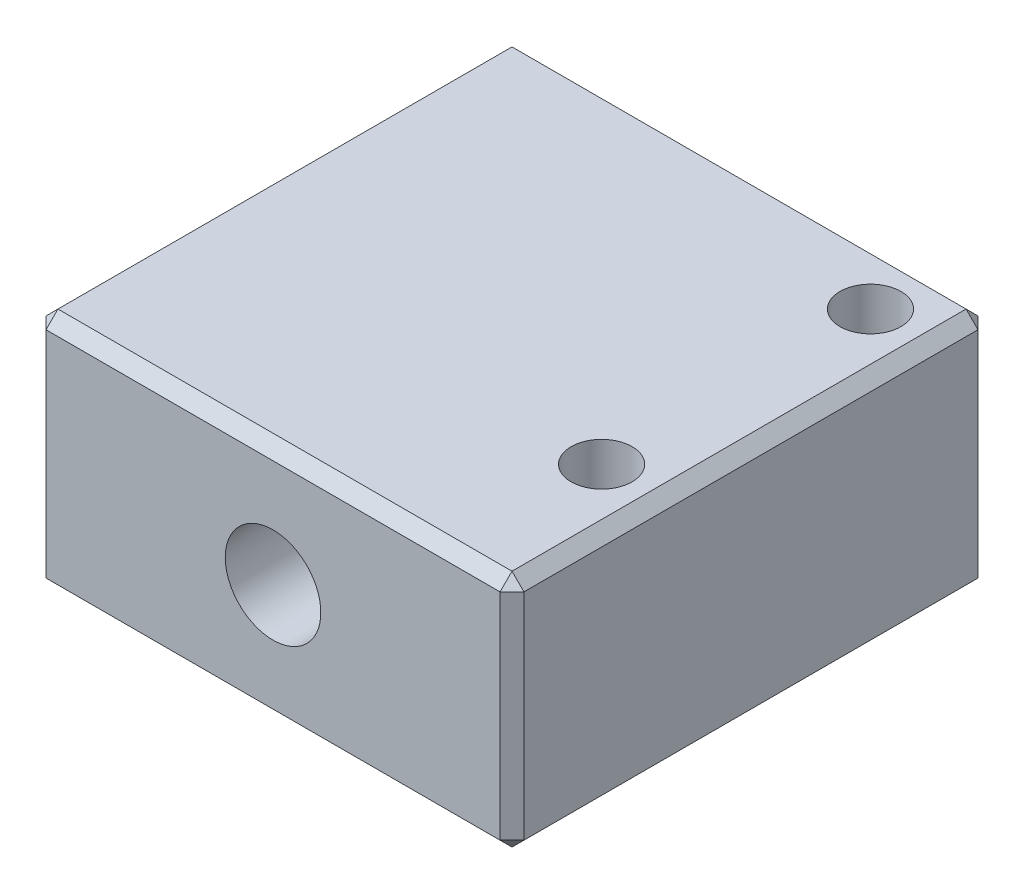
from build123d import *

# Parameters (mm, degrees)
SKETCH1_W               = 40
SKETCH1_H               = 40
BOSS_EXTRUDE1_DEPTH     = 20
SKETCH2_R               = 5.6
CUT_EXTRUDE1_DEPTH      = 10
CHAMFER1_SIZE           = 1
F_1_4_20_TAPPED_HOLE1_D = 5.1054
SKETCH5_R               = 4
CUT_EXTRUDE2_DEPTH      = 41


with BuildPart() as part:
    # Sketch1 → Boss-Extrude1 (new body)
    with BuildSketch(Plane(origin=(0, 0, 0), x_dir=(1, 0, 0), z_dir=(0, 1, 0))):
        Rectangle(SKETCH1_W, SKETCH1_H)
    extrude(amount=BOSS_EXTRUDE1_DEPTH)

    # Sketch2 → Cut-Extrude1 (cut)
    with BuildSketch(Plane.ZY.offset(20)):
        with Locations((-10, 10)):
            Circle(SKETCH2_R)
    extrude(amount=-CUT_EXTRUDE1_DEPTH, mode=Mode.SUBTRACT)

    # Chamfer1
    chamfer1_edges = [part.edges().sort_by_distance(p)[0] for p in [
        (-20, 20, 0),
        (0, 20, 20),
        (20, 20, 0),
        (0, 0, 20),
        (-20, 0, 0),
        (0, 0, -20),
        (20, 0, 0),
        (0, 20, -20),
        (20, 10, 20),
        (-20, 10, 20),
        (-20, 10, -20),
        (20, 10, -20),
    ]]
    chamfer(chamfer1_edges, length=CHAMFER1_SIZE)

    # 1/4-20 Tapped Hole1 (through all)
    with Locations(Plane(origin=(0, 20, 0), x_dir=(1, 0, 0), z_dir=(0, 1, 0))):
        with Locations((15, -7.5), (15, 15)):
            Hole(F_1_4_20_TAPPED_HOLE1_D / 2)

    # Sketch5 → Cut-Extrude2 (cut, through all)
    with BuildSketch(Plane(origin=(0, 0, -20), x_dir=(-1, 0, 0), z_dir=(0, 0, -1))):
        with Locations((0, 10)):
            Circle(SKETCH5_R)
    extrude(amount=-CUT_EXTRUDE2_DEPTH, mode=Mode.SUBTRACT)


solid = part.part
